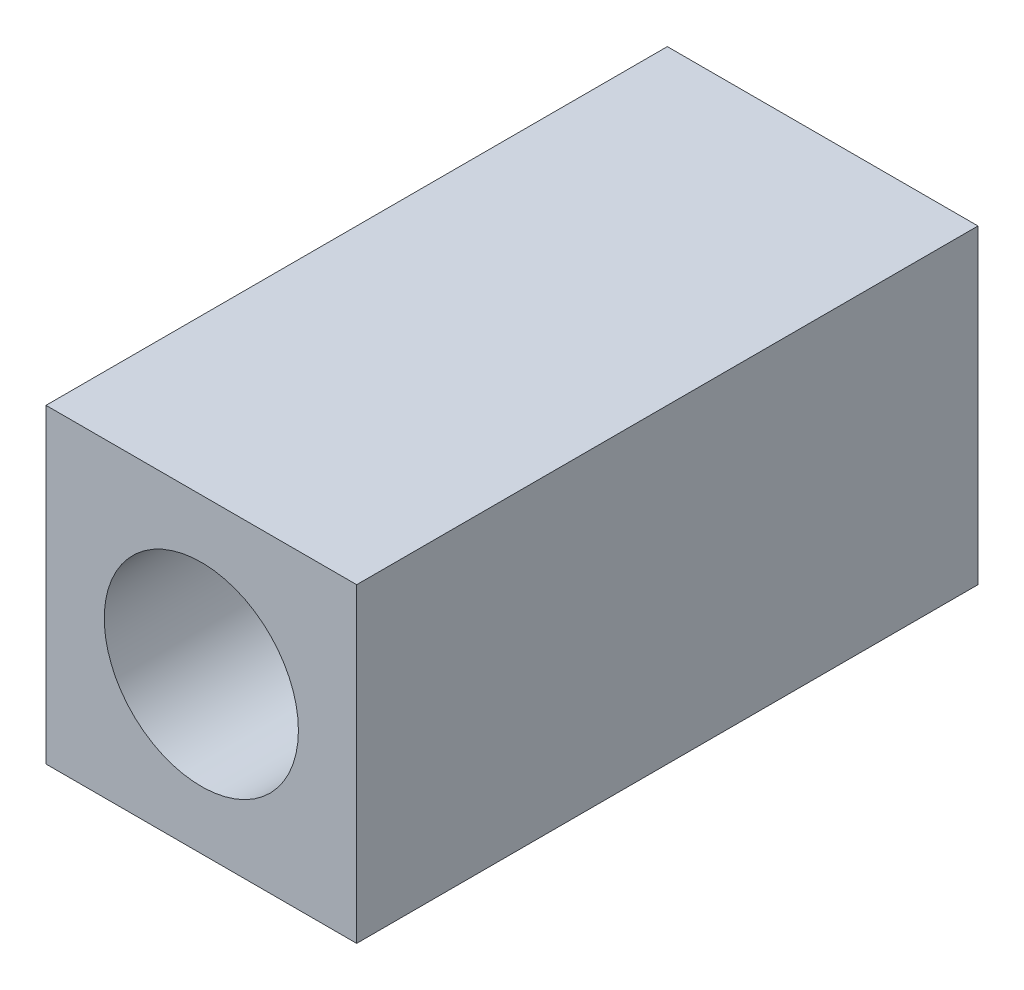
from build123d import *

# Parameters (mm, degrees)
SKETCH1_W           = 12.7
SKETCH1_H           = 12.7
BOSS_EXTRUDE1_DEPTH = 25.4
SKETCH2_R           = 3.175
CUT_EXTRUDE1_DEPTH  = 12.7
SKETCH3_R           = 3.96875
CUT_EXTRUDE2_DEPTH  = 12.7


with BuildPart() as part:
    # Sketch1 → Boss-Extrude1 (new body)
    with BuildSketch(Plane.XY):
        Rectangle(SKETCH1_W, SKETCH1_H)
    extrude(amount=BOSS_EXTRUDE1_DEPTH)

    # Sketch2 → Cut-Extrude1 (cut)
    with BuildSketch(Plane(origin=(0, 0, 0), x_dir=(-1, 0, 0), z_dir=(0, 0, -1))):
        Circle(SKETCH2_R)
    extrude(amount=-CUT_EXTRUDE1_DEPTH, mode=Mode.SUBTRACT)

    # Sketch3 → Cut-Extrude2 (cut)
    with BuildSketch(Plane.XY.offset(25.4)):
        Circle(SKETCH3_R)
    extrude(amount=-CUT_EXTRUDE2_DEPTH, mode=Mode.SUBTRACT)


solid = part.part
